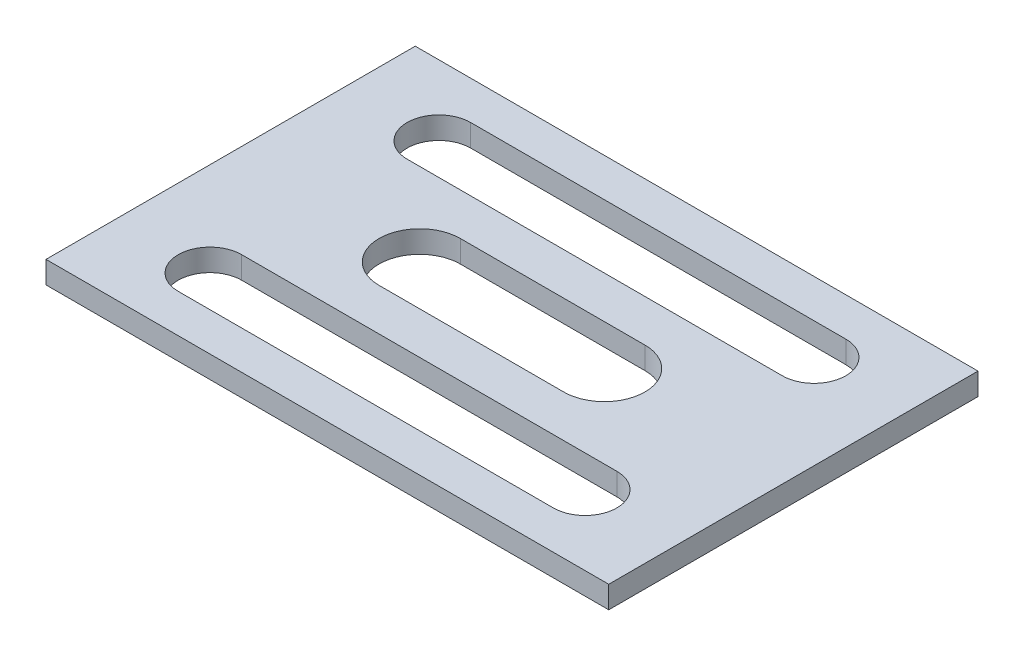
from build123d import *

# Parameters (mm, degrees)
SKETCH1_W           = 76.2
SKETCH1_H           = 50
BOSS_EXTRUDE1_DEPTH = 3
CUT_EXTRUDE1_DEPTH  = 4


with BuildPart() as part:
    # Sketch1 → Boss-Extrude1 (new body)
    with BuildSketch(Plane(origin=(0, 0, 0), x_dir=(1, 0, 0), z_dir=(0, 1, 0))):
        Rectangle(SKETCH1_W, SKETCH1_H)
    extrude(amount=BOSS_EXTRUDE1_DEPTH)

    # Sketch2 → Cut-Extrude1 (cut, through all)
    with BuildSketch(Plane(origin=(0, 3, 0), x_dir=(1, 0, 0), z_dir=(0, 1, 0))):
        with BuildLine():
            Line((-25.4, 19.8), (25.4, 19.8))
            ThreePointArc((25.4, 19.8), (29.7, 15.5), (25.4, 11.2))
            Line((25.4, 11.2), (-25.4, 11.2))
            ThreePointArc((-25.4, 11.2), (-29.7, 15.5), (-25.4, 19.8))
        make_face()
        with BuildLine():
            Line((-25.4, -19.8), (25.4, -19.8))
            ThreePointArc((25.4, -19.8), (29.7, -15.5), (25.4, -11.2))
            Line((25.4, -11.2), (-25.4, -11.2))
            ThreePointArc((-25.4, -11.2), (-29.7, -15.5), (-25.4, -19.8))
        make_face()
        with BuildLine():
            Line((-12.5, 5.5), (12.5, 5.5))
            ThreePointArc((12.5, 5.5), (18, 0), (12.5, -5.5))
            Line((12.5, -5.5), (-12.5, -5.5))
            ThreePointArc((-12.5, -5.5), (-18, 0), (-12.5, 5.5))
        make_face()
    extrude(amount=-CUT_EXTRUDE1_DEPTH, mode=Mode.SUBTRACT)


solid = part.part
